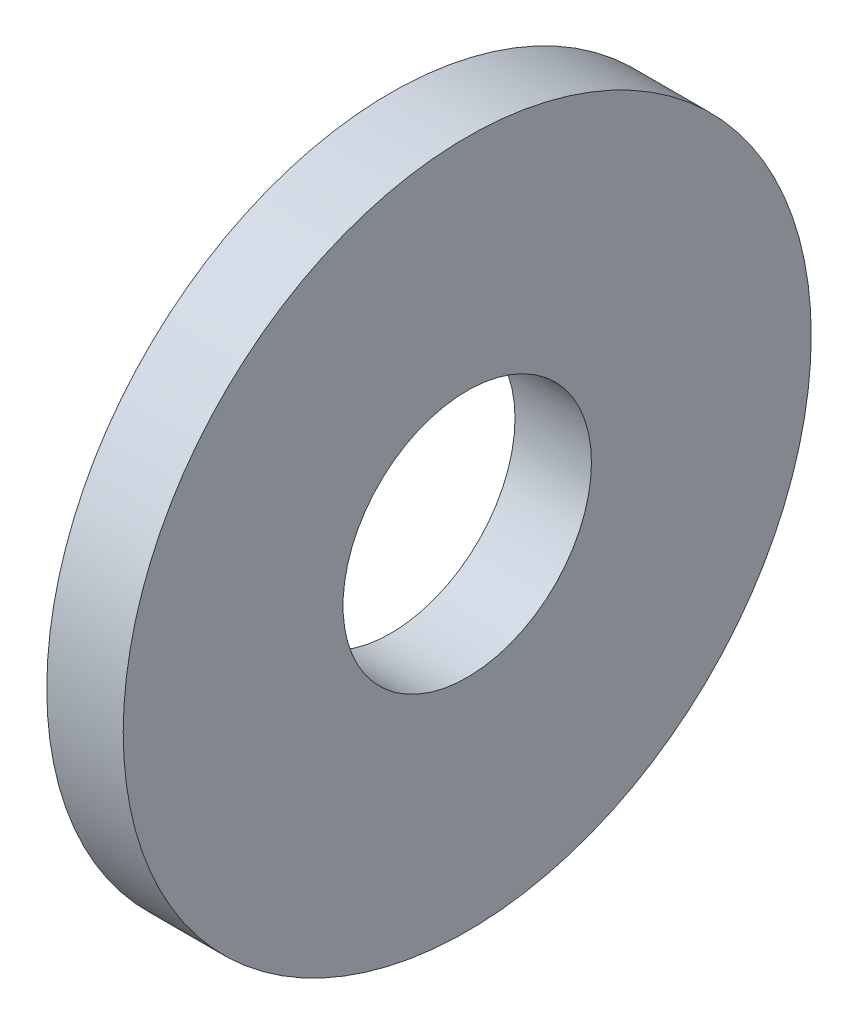
from build123d import *

# Parameters (mm, degrees)
SKETCH1_R           = 9
BOSS_EXTRUDE1_DEPTH = 2
SKETCH2_R           = 3.25
CUT_EXTRUDE1_DEPTH  = 3


with BuildPart() as part:
    # Sketch1 → Boss-Extrude1 (new body)
    with BuildSketch(Plane(origin=(0, 0, 0), x_dir=(0, 0, -1), z_dir=(1, 0, 0))):
        Circle(SKETCH1_R)
    extrude(amount=BOSS_EXTRUDE1_DEPTH)

    # Sketch2 → Cut-Extrude1 (cut, through all)
    with BuildSketch(Plane(origin=(2, 0, 0), x_dir=(0, 0, -1), z_dir=(1, 0, 0))):
        Circle(SKETCH2_R)
    extrude(amount=-CUT_EXTRUDE1_DEPTH, mode=Mode.SUBTRACT)


solid = part.part
